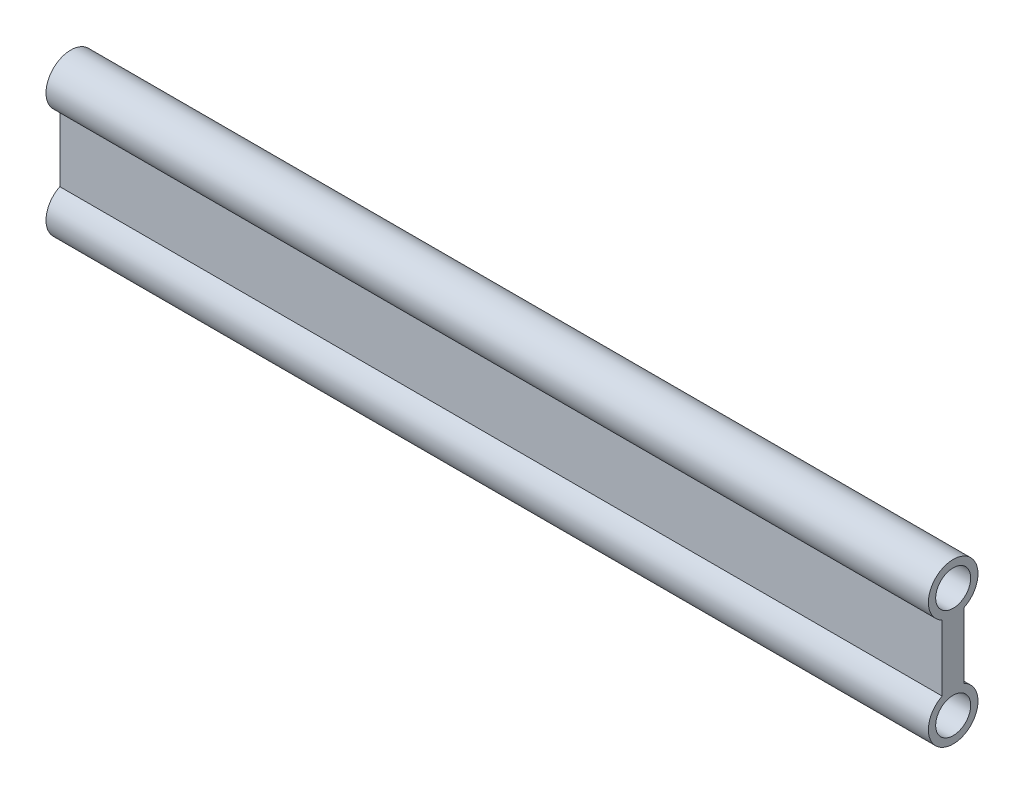
from build123d import *

# Parameters (mm, degrees)
SKETCH1_R           = 3.175
BOSS_EXTRUDE1_DEPTH = 160


with BuildPart() as part:
    # Sketch1 → Boss-Extrude1 (new body)
    with BuildSketch(Plane(origin=(0, 0, 0), x_dir=(0, 0, -1), z_dir=(1, 0, 0))):
        with BuildLine():
            Line((-2, 15.968871126), (-2, 4.031128874))
            ThreePointArc((-2, 4.031128874), (0, -4.5), (2, 4.031128874))
            Line((2, 4.031128874), (2, 15.968871126))
            ThreePointArc((2, 15.968871126), (0, 24.5), (-2, 15.968871126))
        make_face()
        Circle(SKETCH1_R, mode=Mode.SUBTRACT)
        with Locations((0, 20)):
            Circle(SKETCH1_R, mode=Mode.SUBTRACT)
    extrude(amount=BOSS_EXTRUDE1_DEPTH)


solid = part.part
